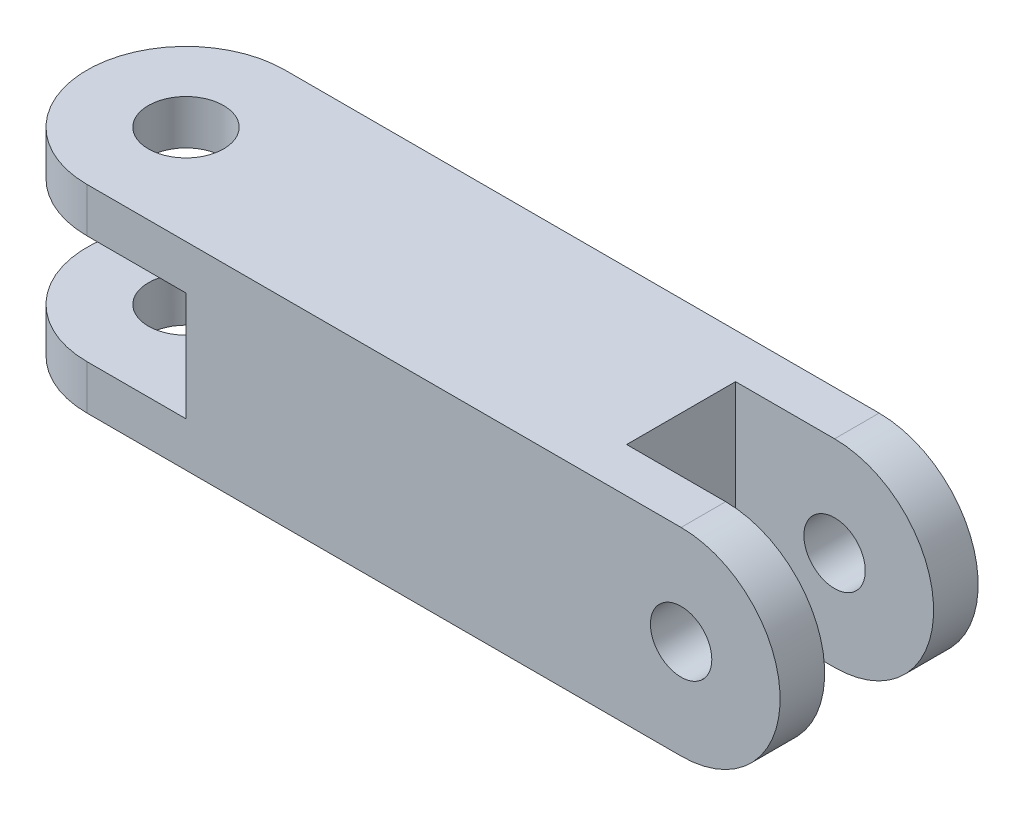
from build123d import *

# Parameters (mm, degrees)
SKETCH1_W            = 30
SKETCH1_H            = 10
BOSS_EXTRUDE1_DEPTH  = 10
SKETCH2_R            = 5
BOSS_EXTRUDE2_DEPTH  = 2.25
BOSS_EXTRUDE4_DEPTH  = 2.25
MIRROR4_COPY_1_DEPTH = 2.25
MIRROR4_COPY_2_DEPTH = 2.25
SKETCH4_R            = 1.9
CUT_EXTRUDE1_DEPTH   = 13.25
SKETCH5_R            = 1.55
CUT_EXTRUDE2_DEPTH   = 13.25
SKETCH6_W            = 5
SKETCH6_H            = 5.5
CUT_EXTRUDE3_DEPTH   = 13.25
SKETCH7_W            = 5
SKETCH7_H            = 5.5
CUT_EXTRUDE4_DEPTH   = 13.25


with BuildPart() as part:
    # Sketch1 → Boss-Extrude1 (new body)
    with BuildSketch(Plane.XY):
        with Locations((-9.058394161, -0.861313869)):
            Rectangle(SKETCH1_W, SKETCH1_H)
    extrude(amount=BOSS_EXTRUDE1_DEPTH)

    # Sketch2 → Boss-Extrude2 (add)
    with BuildSketch(Plane.XY.offset(10)):
        with Locations((5.941605839, -0.861313869)):
            Circle(SKETCH2_R)
    boss_extrude2 = extrude(amount=-BOSS_EXTRUDE2_DEPTH)

    # Sketch3 → Boss-Extrude4 (add)
    with BuildSketch(Plane(origin=(0, 4.138686131, 0), x_dir=(1, 0, 0), z_dir=(0, 1, 0))):
        with BuildLine():
            Line((-24.058394161, -10), (-24.058394161, -5))
            Line((-24.058394161, -5), (-29.058394161, -5))
            ThreePointArc((-29.058394161, -5), (-27.593928067, -8.535533906), (-24.058394161, -10))
        make_face()
    boss_extrude4 = extrude(amount=-BOSS_EXTRUDE4_DEPTH)

    # Mirror1: Boss-Extrude2, Boss-Extrude4 across plane
    add(boss_extrude2.mirror(Plane(origin=(0, 0, 5), x_dir=(1, 0, 0), z_dir=(0, 0, -1))))
    add(boss_extrude4.mirror(Plane(origin=(0, 0, 5), x_dir=(1, 0, 0), z_dir=(0, 0, -1))))

    # Mirror3: Boss-Extrude4 across plane
    add(boss_extrude4.mirror(Plane.ZX.offset(-0.861313869)))

    # Mirror4 copy 1 sketch → Mirror4 copy 1 (add)
    with BuildSketch(Plane(origin=(0, -5.861313869, 10), x_dir=(1, 0, 0), z_dir=(0, -1, 0))):
        with BuildLine():
            Line((-24.058394161, -10), (-24.058394161, -5))
            Line((-24.058394161, -5), (-29.058394161, -5))
            ThreePointArc((-29.058394161, -5), (-27.593928067, -8.535533906), (-24.058394161, -10))
        make_face()
    extrude(amount=-MIRROR4_COPY_1_DEPTH)

    # Mirror4 copy 2 sketch → Mirror4 copy 2 (add)
    with BuildSketch(Plane(origin=(0, 4.138686131, 10), x_dir=(1, 0, 0), z_dir=(0, 1, 0))):
        with BuildLine():
            Line((-24.058394161, 10), (-24.058394161, 5))
            Line((-24.058394161, 5), (-29.058394161, 5))
            ThreePointArc((-29.058394161, 5), (-27.593928067, 8.535533906), (-24.058394161, 10))
        make_face()
    extrude(amount=-MIRROR4_COPY_2_DEPTH)

    # Sketch4 → Cut-Extrude1 (cut)
    with BuildSketch(Plane(origin=(0, 4.138686131, 0), x_dir=(1, 0, 0), z_dir=(0, 1, 0))):
        with Locations(Location((-24.058394161, -5, 0), (0, 0, 270))):  # turned: the seam where the file's is
            Circle(SKETCH4_R)
    extrude(amount=-CUT_EXTRUDE1_DEPTH, mode=Mode.SUBTRACT)

    # Sketch5 → Cut-Extrude2 (cut)
    with BuildSketch(Plane(origin=(0, 0, 0), x_dir=(-1, 0, 0), z_dir=(0, 0, -1))):
        with Locations((-5.941605839, -0.861313869)):
            Circle(SKETCH5_R)
    extrude(amount=-CUT_EXTRUDE2_DEPTH, mode=Mode.SUBTRACT)

    # Sketch6 → Cut-Extrude3 (cut)
    with BuildSketch(Plane(origin=(0, 4.138686131, 0), x_dir=(1, 0, 0), z_dir=(0, 1, 0))):
        with Locations((3.441605839, -5)):
            Rectangle(SKETCH6_W, SKETCH6_H)
    extrude(amount=-CUT_EXTRUDE3_DEPTH, mode=Mode.SUBTRACT)

    # Sketch7 → Cut-Extrude4 (cut)
    with BuildSketch(Plane.XY.offset(10)):
        with Locations((-21.558394161, -0.861313869)):
            Rectangle(SKETCH7_W, SKETCH7_H)
    extrude(amount=-CUT_EXTRUDE4_DEPTH, mode=Mode.SUBTRACT)


solid = part.part
